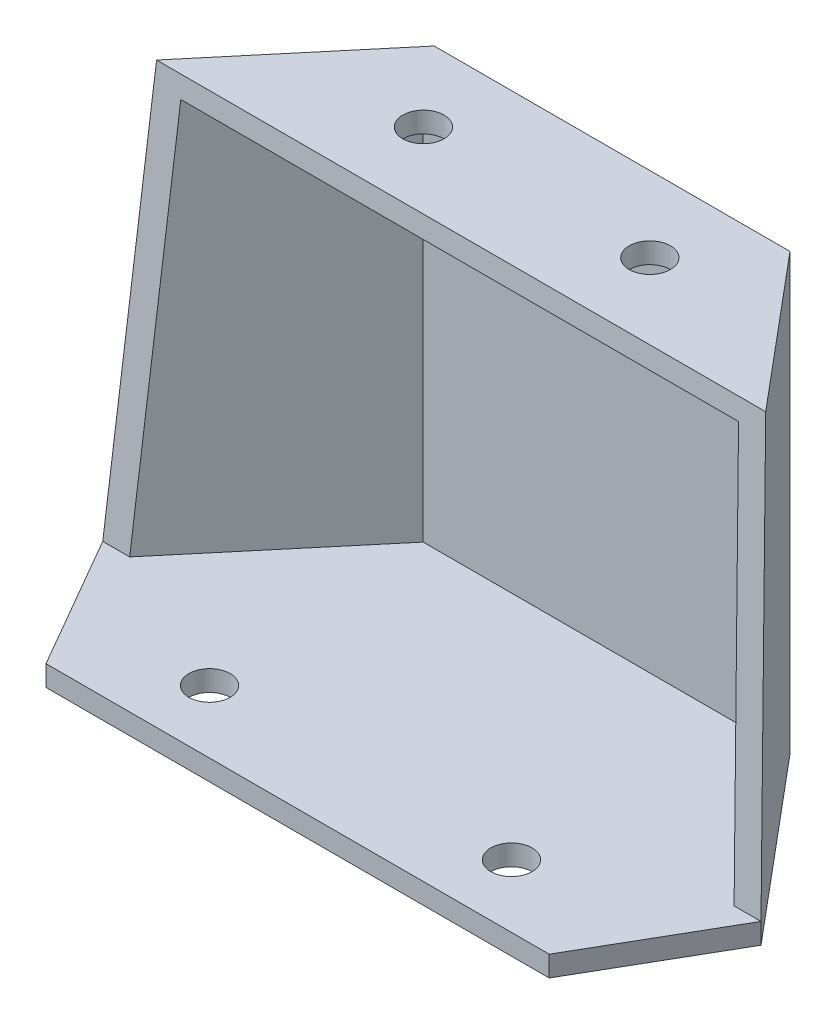
from build123d import *

# Parameters (mm, degrees)
EXTRUDE_1_DEPTH          = 211
SHELL_2_T                = 10
CUT_EXTRUDE_2_DEPTH      = 306.363666708
CUT_EXTRUDE_2_DEPTH_BACK = 306.363666708
SKETCH_8_R               = 10
CUT_EXTRUDE_6_DEPTH      = 10
SKETCH_13_R              = 10
CUT_EXTRUDE_7_DEPTH      = 10


with BuildPart() as part:
    # 草图1 → 凸台-拉伸1 (new body)
    with BuildSketch(Plane(origin=(0, 0, 0), x_dir=(1, 0, 0), z_dir=(0, 1, 0))):
        Polygon((0, 152.5), (0, 0), (122, 0), (159.592352403, 65.111864338), (86.265, 152.5), align=None)
        Polygon((-122, 0), (0, 0), (0, 152.5), (-86.265, 152.5), (-159.592352403, 65.111864338), align=None)
    extrude(amount=EXTRUDE_1_DEPTH)

    # 抽壳2 (no face opened: a closed hollow body)
    add(offset(amount=-SHELL_2_T, mode=Mode.PRIVATE), mode=Mode.SUBTRACT)

    # 草图5 → 切除-拉伸-薄壁2 (cut, two sides)
    with BuildSketch(Plane(origin=(0, 0, 0), x_dir=(0, 0, -1), z_dir=(1, 0, 0))) as cut_extrude_2_sk:
        Polygon((79.3, 211), (65.111864338, 10), (0, 10), (0, 211), (10, 211), (10, 20), (55.792859546, 20), (69.32482043, 211.704125378), align=None)
    extrude(amount=CUT_EXTRUDE_2_DEPTH, mode=Mode.SUBTRACT)
    extrude(cut_extrude_2_sk.sketch, amount=-CUT_EXTRUDE_2_DEPTH_BACK, mode=Mode.SUBTRACT)


with BuildPart() as cut_extrude_2_kept_piece:
    # of the separate pieces the step leaves, the one the design keeps (cut_extrude_2_pieces_kept)
    add(part.part.solids().sort_by_distance((122, 0, 0))[0])

    # 草图8 → 切除-拉伸6 (cut)
    with BuildSketch(Plane(origin=(0, 211, 0), x_dir=(1, 0, 0), z_dir=(0, 1, 0))):
        with Locations(Location((-54.9, 115.9, 0), (0, 0, 270))):
            Circle(SKETCH_8_R)
        with Locations(Location((54.9, 115.9, 0), (0, 0, 90))):
            Circle(SKETCH_8_R)
    extrude(amount=-CUT_EXTRUDE_6_DEPTH, mode=Mode.SUBTRACT)

    # 草图13 → 切除-拉伸7 (cut)
    with BuildSketch(Plane(origin=(0, 10, 0), x_dir=(1, 0, 0), z_dir=(0, 1, 0))):
        with Locations(Location((-73.2, 30.5, 0), (0, 0, 270))):
            Circle(SKETCH_13_R)
        with Locations(Location((73.2, 30.5, 0), (0, 0, 90))):
            Circle(SKETCH_13_R)
    extrude(amount=-CUT_EXTRUDE_7_DEPTH, mode=Mode.SUBTRACT)


solid = cut_extrude_2_kept_piece.part
